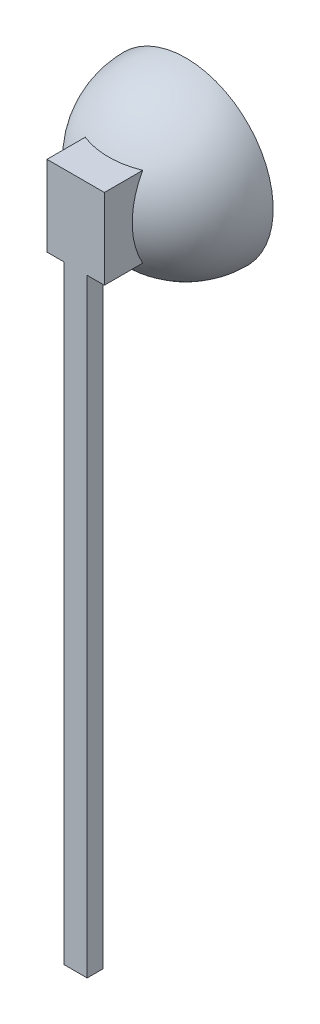
from build123d import *

# Parameters (mm, degrees)
REVOLVE1_ANGLE                  = 180
BOSS_EXTRUDE2_REACH             = 67.818
SKETCH2_W                       = 25
SKETCH2_H                       = 35
BOSS_EXTRUDE2_DIRECTION_2_DEPTH = 10
SKETCH5_W                       = 10
SKETCH5_H                       = 300
BOSS_EXTRUDE3_DEPTH             = 7
SKETCH6_W                       = 7
SKETCH6_H                       = 4.5
CUT_EXTRUDE1_DEPTH              = 265


with BuildPart() as part:
    # Sketch1 → Revolve1 (revolve)
    with BuildSketch(Plane.XY):
        with BuildLine():
            Line((0, 38), (0, 33))
            ThreePointArc((0, 33), (33, 0), (0, -33))
            Line((0, -33), (0, -38))
            ThreePointArc((0, -38), (38, 0), (0, 38))
        make_face()
    revolve(axis=Axis((0, -33, 0), (0, -1, 0)), revolution_arc=REVOLVE1_ANGLE)

    # Sketch2 → Boss-Extrude2 (add, up to next)
    with BuildSketch(Plane(origin=(0, 0, 38), x_dir=(-1, 0, 0), z_dir=(0, 0, -1)), mode=Mode.PRIVATE) as boss_extrude2_sk1:
        Rectangle(SKETCH2_W, SKETCH2_H)
    boss_extrude2_tool1 = extrude(boss_extrude2_sk1.sketch, amount=BOSS_EXTRUDE2_REACH, mode=Mode.PRIVATE) - part.part
    add(boss_extrude2_tool1.solids().sort_by_distance((0, 0, 38))[0])

    # Sketch2 → Boss-Extrude2 direction 2 (add)
    with BuildSketch(Plane(origin=(0, 0, 38), x_dir=(-1, 0, 0), z_dir=(0, 0, -1))):
        Rectangle(SKETCH2_W, SKETCH2_H)
    extrude(amount=-BOSS_EXTRUDE2_DIRECTION_2_DEPTH)

    # Sketch5 → Boss-Extrude3 (add)
    with BuildSketch(Plane.XY.offset(48)):
        with Locations((0, -132.5)):
            Rectangle(SKETCH5_W, SKETCH5_H)
    extrude(amount=-BOSS_EXTRUDE3_DEPTH)

    # Sketch6 → Cut-Extrude1 (cut)
    with BuildSketch(Plane(origin=(0, -282.5, 0), x_dir=(-1, 0, 0), z_dir=(0, -1, 0))):
        with Locations((0, -44.5)):
            Rectangle(SKETCH6_W, SKETCH6_H)
    extrude(amount=-CUT_EXTRUDE1_DEPTH, mode=Mode.SUBTRACT)


solid = part.part
